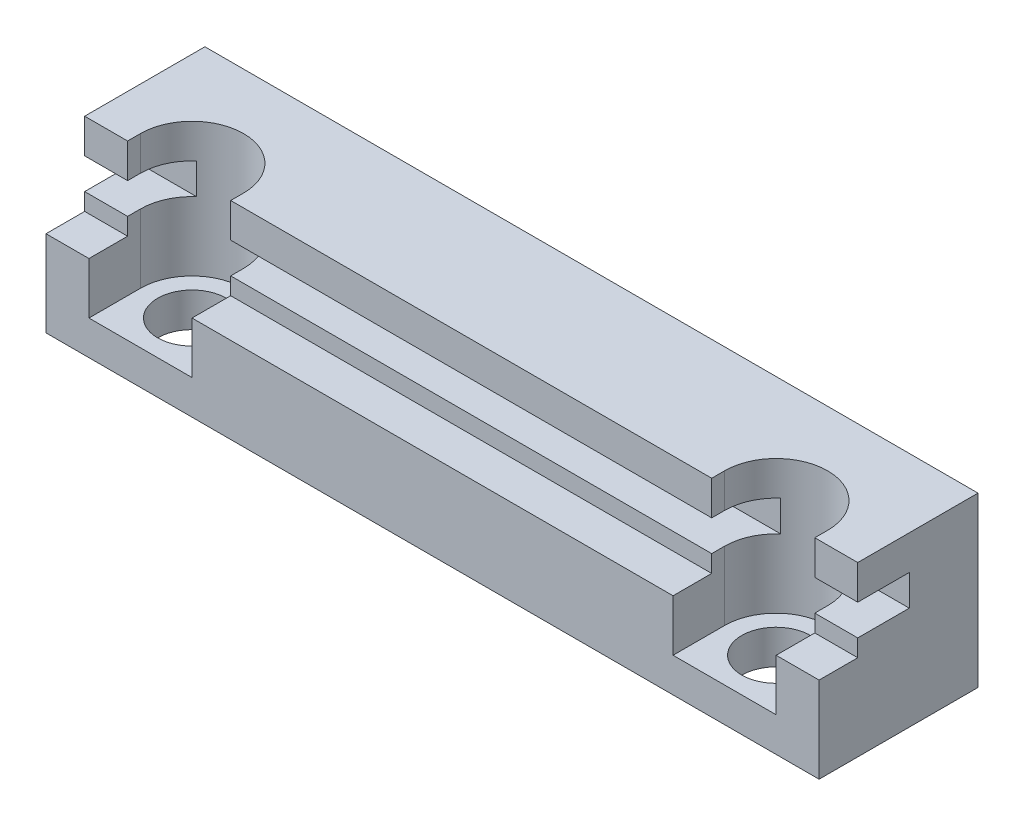
from build123d import *

# Parameters (mm, degrees)
EXTRUDE_1_DEPTH     = 45
SKETCH_2_R          = 2
CUT_EXTRUDE_1_DEPTH = 10.8
CUT_EXTRUDE_2_DEPTH = 7.8


with BuildPart() as part:
    # Эскиз1 → Бобышка-Вытянуть1 (new body)
    with BuildSketch(Plane(origin=(0, 0, 0), x_dir=(0, 0, -1), z_dir=(1, 0, 0))):
        Polygon((0, 5), (0, 6), (3, 6), (3, 7.8), (0, 7.8), (0, 9.8), (7, 9.8), (7, 0), (0, 0), (-2.25, 0), (-2.25, 5), align=None)
    extrude(amount=EXTRUDE_1_DEPTH)

    # Эскиз2 → Вырез-Вытянуть1 (cut, through all)
    with BuildSketch(Plane(origin=(0, 9.8, 0), x_dir=(1, 0, 0), z_dir=(0, 1, 0))):
        with Locations((5.5, 0.75)):
            Circle(SKETCH_2_R)
        with Locations((39.5, 0.75)):
            Circle(SKETCH_2_R)
    extrude(amount=-CUT_EXTRUDE_1_DEPTH, mode=Mode.SUBTRACT)

    # Эскиз3 → Вырез-Вытянуть2 (cut)
    with BuildSketch(Plane(origin=(0, 9.8, 0), x_dir=(1, 0, 0), z_dir=(0, 1, 0))):
        with BuildLine():
            Line((2.5, 0.75), (2.5, -2.25))
            Line((2.5, -2.25), (8.5, -2.25))
            Line((8.5, -2.25), (8.5, 0.75))
            ThreePointArc((8.5, 0.75), (5.5, 3.75), (2.5, 0.75))
        make_face()
        with BuildLine():
            Line((36.5, 0.75), (36.5, -2.25))
            Line((36.5, -2.25), (42.5, -2.25))
            Line((42.5, -2.25), (42.5, 0.75))
            ThreePointArc((42.5, 0.75), (39.5, 3.75), (36.5, 0.75))
        make_face()
    extrude(amount=-CUT_EXTRUDE_2_DEPTH, mode=Mode.SUBTRACT)


solid = part.part
